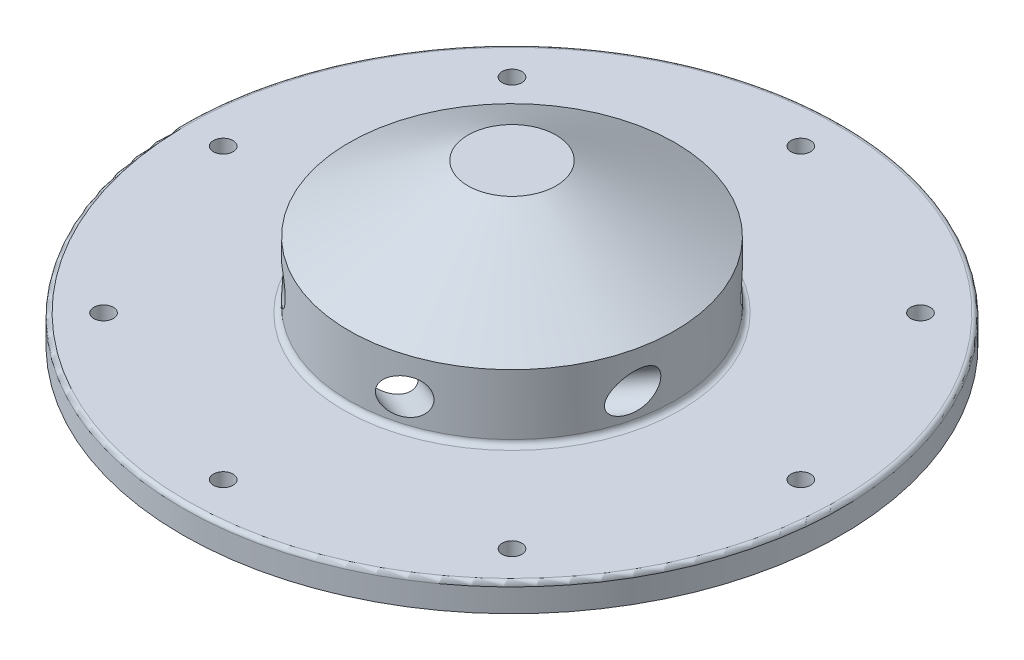
from build123d import *

# Parameters (mm, degrees)
SKETCH2_R                 = 38.04031
BOSS_EXTRUDE1_DEPTH       = 3.175
TAP_DRILL_FOR_4_40_TAP1_D = 2.2606
CIRPATTERN1_COUNT         = 8
SKETCH7_R                 = 18.81
BOSS_EXTRUDE2_DEPTH       = 7.62
SKETCH8_R                 = 15
CUT_EXTRUDE1_DEPTH        = 8.89
SKETCH14_R                = 5.08
SKETCH13_R                = 18.81
FILLET1_R                 = 0.635
FILLET3_R                 = 0.5
FILLET2_R                 = 0.635
SKETCH16_R                = 1.98
CUT_EXTRUDE2_DEPTH        = 40.538069487
CIRPATTERN2_COUNT         = 6


with BuildPart() as part:
    # Sketch2 → Boss-Extrude1 (new body)
    with BuildSketch(Plane(origin=(0, 0, 0), x_dir=(1, 0, 0), z_dir=(0, 1, 0))):
        Circle(SKETCH2_R)
    extrude(amount=BOSS_EXTRUDE1_DEPTH)

    # Tap Drill for _4-40 Tap1 (through all)
    with Locations(Plane(origin=(0, 0, 0), x_dir=(-1, 0, 0), z_dir=(0, -1, 0))):
        with Locations((0, -33.3375)):
            tap_drill_for_4_40_tap1 = Hole(TAP_DRILL_FOR_4_40_TAP1_D / 2)

    # CirPattern1: Tap Drill for _4-40 Tap1 ×8 about axis
    cirpattern1_axis = Axis((0, 0, 0), (0, 1, 0))
    for i in range(1, CIRPATTERN1_COUNT):
        add(tap_drill_for_4_40_tap1.rotate(cirpattern1_axis, i * 360 / CIRPATTERN1_COUNT), mode=Mode.SUBTRACT)

    # Sketch7 → Boss-Extrude2 (add)
    with BuildSketch(Plane(origin=(0, 3.175, 0), x_dir=(1, 0, 0), z_dir=(0, 1, 0))):
        Circle(SKETCH7_R)
    extrude(amount=BOSS_EXTRUDE2_DEPTH)

    # Sketch8 → Cut-Extrude1 (cut)
    with BuildSketch(Plane.XZ):
        Circle(SKETCH8_R)
    extrude(amount=-CUT_EXTRUDE1_DEPTH, mode=Mode.SUBTRACT)

    # Sketch14 → Loft2 section 0
    with BuildSketch(Plane(origin=(0, 18.415, 0), x_dir=(1, 0, 0), z_dir=(0, 1, 0))):
        Circle(SKETCH14_R)
    # Sketch13 → Loft2 section 1
    with BuildSketch(Plane(origin=(0, 10.795, 0), x_dir=(1, 0, 0), z_dir=(0, 1, 0))):
        Circle(SKETCH13_R)
    loft()

    # Fillet1
    fillet1_edges = [part.edges().sort_by_distance(p)[0] for p in [
        (-15, 8.89, 0),
    ]]
    fillet(fillet1_edges, radius=FILLET1_R)

    # Fillet3
    fillet3_edges = [part.edges().sort_by_distance(p)[0] for p in [
        (-38.04031, 3.175, 0),
    ]]
    fillet(fillet3_edges, radius=FILLET3_R)

    # Fillet2
    fillet2_edges = [part.edges().sort_by_distance(p)[0] for p in [
        (-18.81, 3.175, 0),
    ]]
    fillet(fillet2_edges, radius=FILLET2_R)

    # Sketch16 → Cut-Extrude2 (cut, through all)
    with BuildSketch(Plane(origin=(0, 0.510443212, 1.905), x_dir=(-1, 0, 0), z_dir=(0, 0.258819045, 0.965925826))):
        with Locations((12.71, -2.789932638)):
            Circle(SKETCH16_R)
    cut_extrude2 = extrude(amount=CUT_EXTRUDE2_DEPTH, mode=Mode.SUBTRACT)

    # CirPattern2: Cut-Extrude2 ×6 about axis
    cirpattern2_axis = Axis((0, 0, 0), (0, -1, 0))
    for i in range(1, CIRPATTERN2_COUNT):
        add(cut_extrude2.rotate(cirpattern2_axis, i * 360 / CIRPATTERN2_COUNT), mode=Mode.SUBTRACT)


solid = part.part
